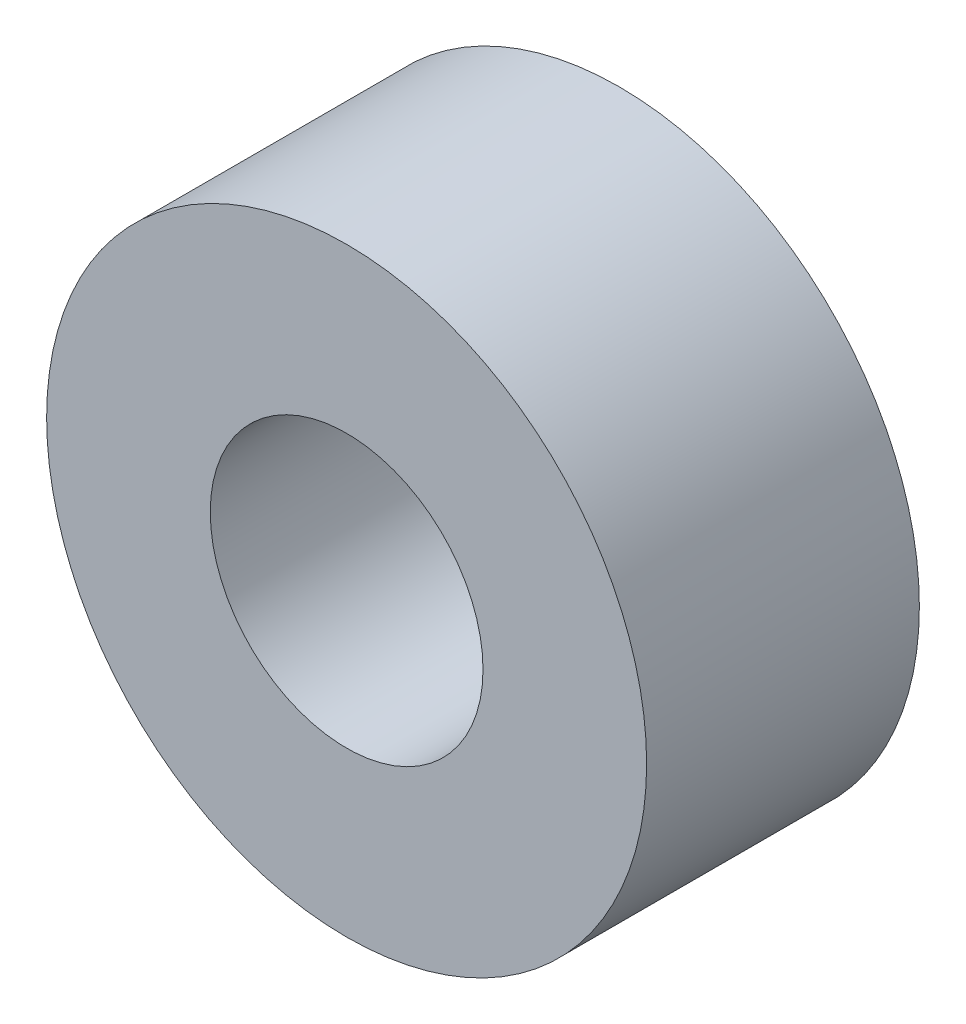
from build123d import *

# Parameters (mm, degrees)
SKETCH1_R           = 5.5
SKETCH1_R_2         = 2.5
BOSS_EXTRUDE1_DEPTH = 5


with BuildPart() as part:
    # Sketch1 → Boss-Extrude1 (new body)
    with BuildSketch(Plane.XY):
        Circle(SKETCH1_R)
        Circle(SKETCH1_R_2, mode=Mode.SUBTRACT)
    extrude(amount=BOSS_EXTRUDE1_DEPTH)


solid = part.part
